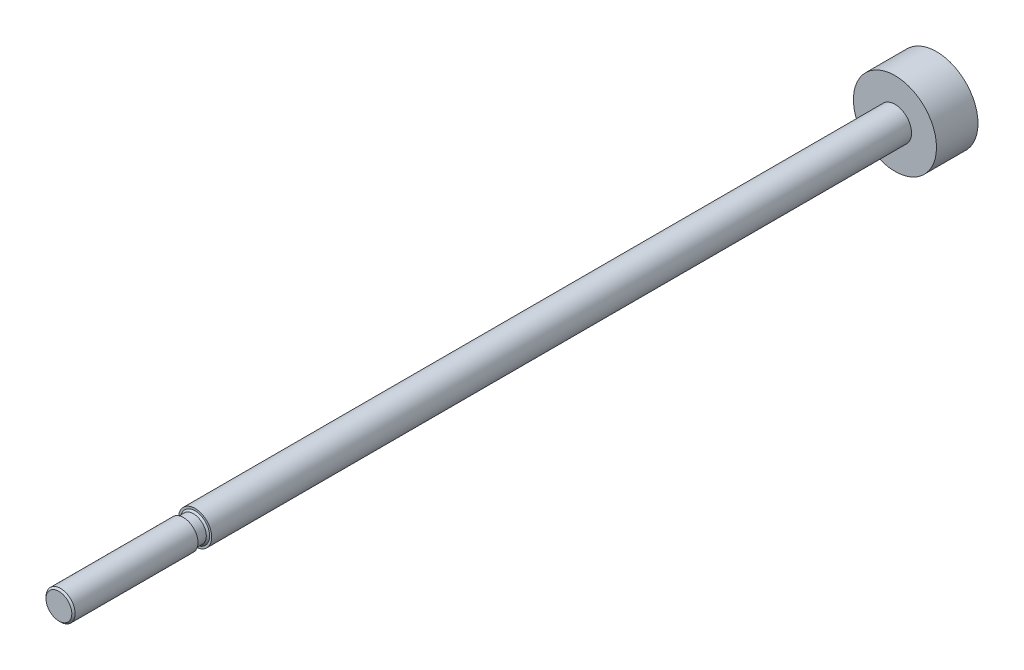
from build123d import *

# Parameters (mm, degrees)
SKETCH1_R          = 2
BASE_EXTRUDE_DEPTH = 103.185
SKETCH2_R          = 5
PISTON_DEPTH       = 2.5


with BuildPart() as part:
    # Sketch1 → Base-Extrude (new body)
    with BuildSketch(Plane.XY):
        Circle(SKETCH1_R)
    extrude(amount=BASE_EXTRUDE_DEPTH)

    # Sketch2 → Piston (add, symmetric)
    with BuildSketch(Plane.XY):
        Circle(SKETCH2_R)
    extrude(amount=PISTON_DEPTH, both=True)

    # Sketch3 → Threads (revolve, cut)
    with BuildSketch(Plane(origin=(0, 0, 0), x_dir=(0, 0, -1), z_dir=(1, 0, 0))):
        Polygon((-103.185, 1.5525), (-102.985, 1.7525), (-88.185, 1.7525), (-88.185, 1.55), (-86.985, 1.55), (-86.785, 1.75), (-86.785, 5), (-103.185, 5), align=None)
    revolve(axis=Axis((0, 0, 0), (0, 0, 1)), mode=Mode.SUBTRACT)


solid = part.part
